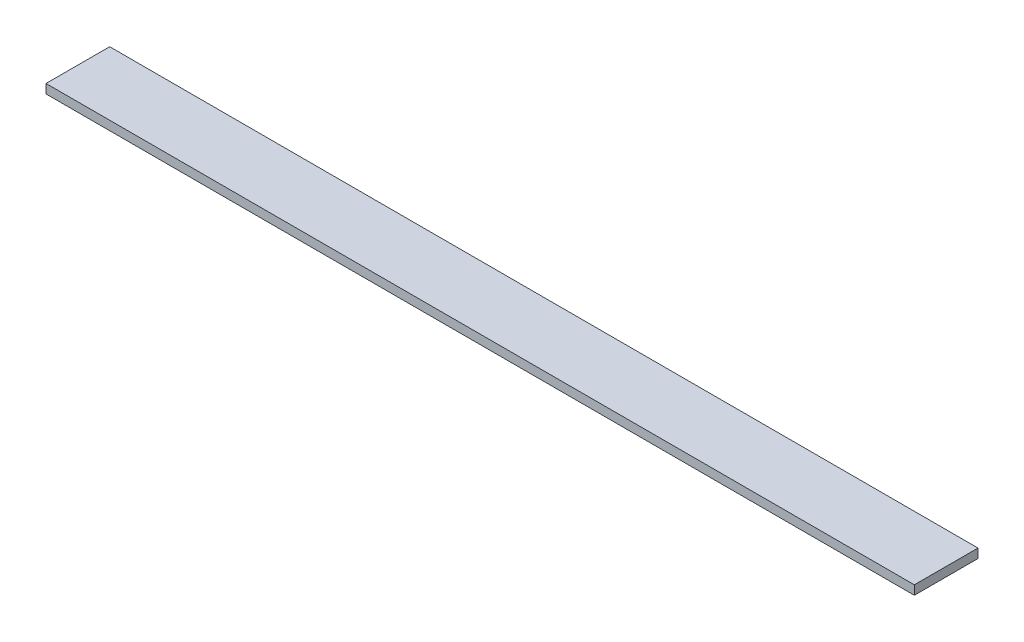
from build123d import *

# Parameters (mm, degrees)
SKETCH1_W           = 86.614
SKETCH1_H           = 6.35
BOSS_EXTRUDE1_DEPTH = 0.90678


with BuildPart() as part:
    # Sketch1 → Boss-Extrude1 (new body)
    with BuildSketch(Plane(origin=(0, 0, 0), x_dir=(1, 0, 0), z_dir=(0, 1, 0))):
        with Locations((43.307, 3.175)):
            Rectangle(SKETCH1_W, SKETCH1_H)
    extrude(amount=BOSS_EXTRUDE1_DEPTH)


solid = part.part
